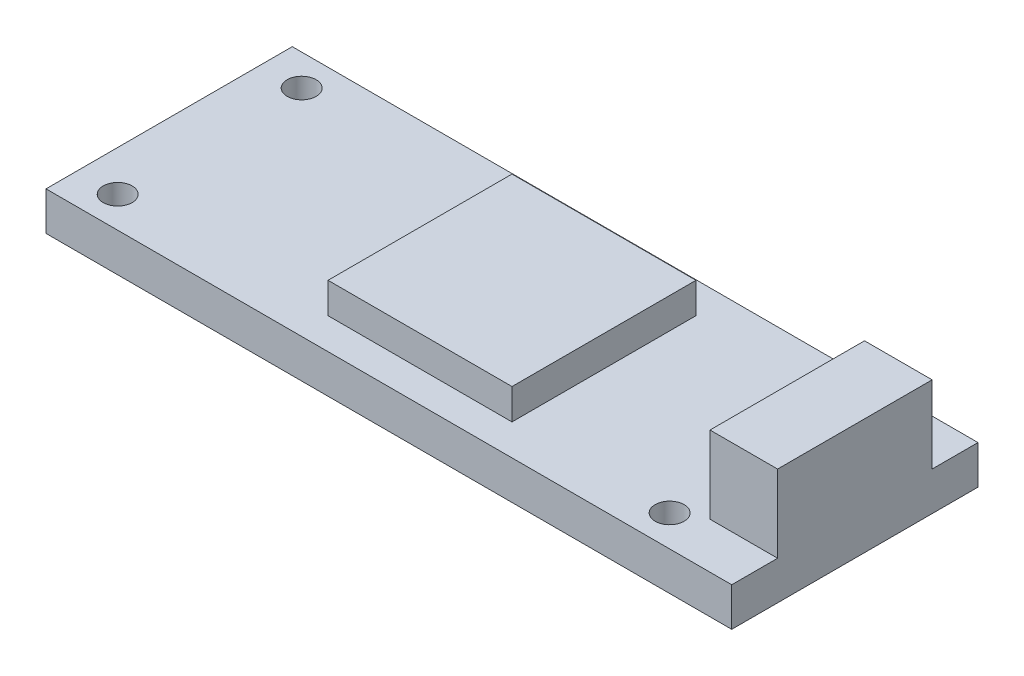
from build123d import *

# Parameters (mm, degrees)
SKETCH1_W           = 71
SKETCH1_H           = 25.5
BOSS_EXTRUDE2_DEPTH = 4
SKETCH4_W           = 7
SKETCH4_H           = 16
BOSS_EXTRUDE3_DEPTH = 8
SKETCH5_W           = 19.05
SKETCH5_H           = 19.05
BOSS_EXTRUDE4_DEPTH = 3.174
SKETCH6_R           = 1.5
CUT_EXTRUDE1_DEPTH  = 5


with BuildPart() as part:
    # Sketch1 → Boss-Extrude2 (new body)
    with BuildSketch(Plane(origin=(0, 0, 0), x_dir=(1, 0, 0), z_dir=(0, 1, 0))):
        Rectangle(SKETCH1_W, SKETCH1_H)
    extrude(amount=BOSS_EXTRUDE2_DEPTH)

    # Sketch4 → Boss-Extrude3 (add)
    with BuildSketch(Plane(origin=(0, 4, 0), x_dir=(1, 0, 0), z_dir=(0, 1, 0))):
        with Locations((32, 0)):
            Rectangle(SKETCH4_W, SKETCH4_H)
    extrude(amount=BOSS_EXTRUDE3_DEPTH)

    # Sketch5 → Boss-Extrude4 (add)
    with BuildSketch(Plane(origin=(0, 4, 0), x_dir=(1, 0, 0), z_dir=(0, 1, 0))):
        Rectangle(SKETCH5_W, SKETCH5_H)
    extrude(amount=BOSS_EXTRUDE4_DEPTH)

    # Sketch6 → Cut-Extrude1 (cut, through all)
    with BuildSketch(Plane(origin=(0, 4, 0), x_dir=(1, 0, 0), z_dir=(0, 1, 0))):
        with Locations((-31.302, 9.525)):
            Circle(SKETCH6_R)
        with Locations((-31.302, -9.525)):
            Circle(SKETCH6_R)
        with Locations((25.848, 9.525)):
            Circle(SKETCH6_R)
        with Locations((25.848, -9.525)):
            Circle(SKETCH6_R)
    extrude(amount=-CUT_EXTRUDE1_DEPTH, mode=Mode.SUBTRACT)


solid = part.part
